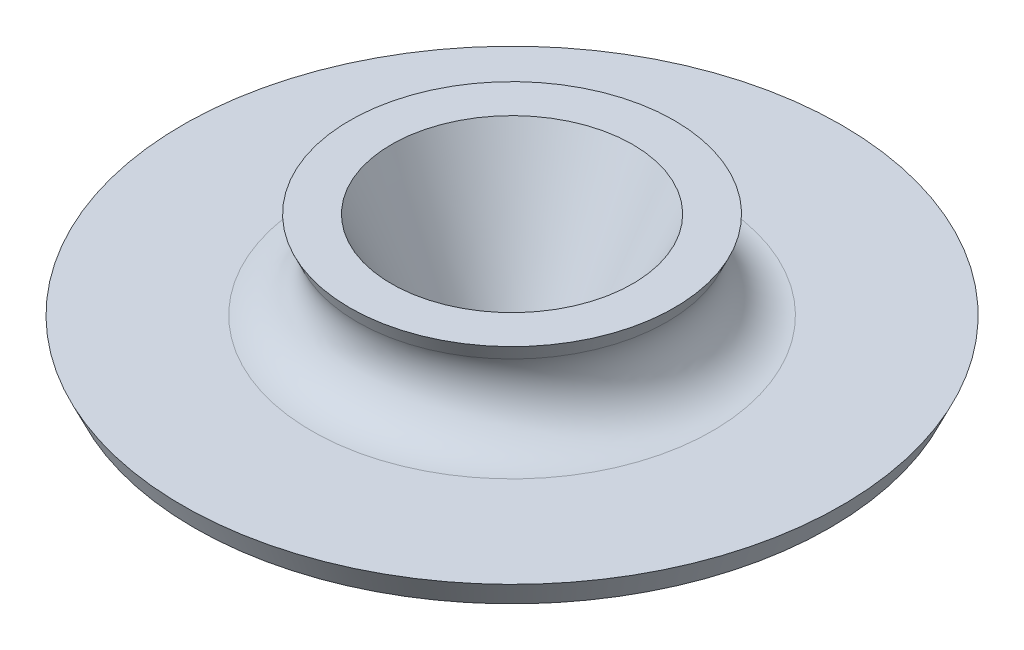
from build123d import *

# Parameters (mm, degrees)
FILLET1_R = 12.7


with BuildPart() as part:
    # Sketch1 → Revolve1 (revolve)
    with BuildSketch(Plane.XY):
        Polygon((-12.7, 0), (-19.706449785, 0), (-24.196413459, 9.62875817), (-80.248011742, 9.62875817), (-83.209065371, 15.97875817), (-30.660691981, 15.97875817), (-40.975996454, 38.1), (-30.466321776, 38.1), align=None)
    revolve(axis=Axis((0, 0, 0), (0, 1, 0)))

    # Fillet1
    fillet1_edges = [part.edges().sort_by_distance(p)[0] for p in [
        (30.660691981, 15.97875817, 0),
    ]]
    fillet(fillet1_edges, radius=FILLET1_R)


solid = part.part
